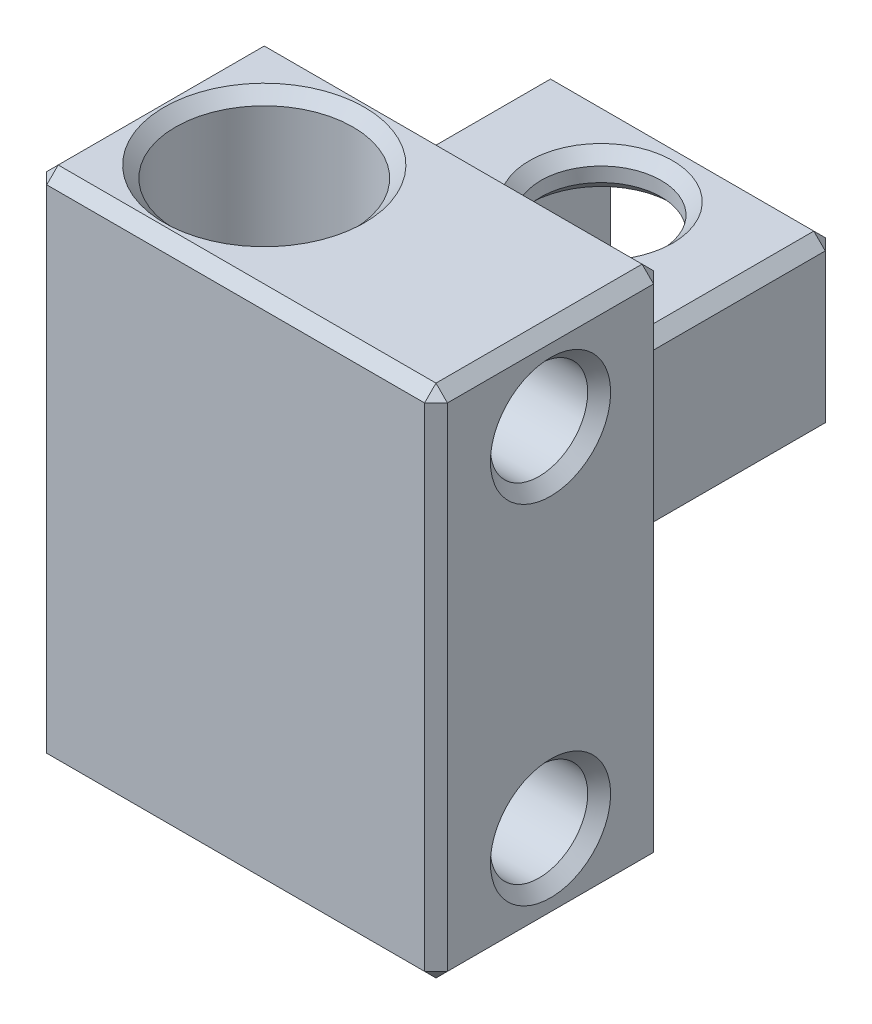
from build123d import *

# Parameters (mm, degrees)
SKETCH1_W               = 35
SKETCH1_H               = 20
BOSS_EXTRUDE1_DEPTH     = 45
SKETCH2_R               = 7.75
CUT_EXTRUDE1_DEPTH      = 46
SKETCH3_R               = 4.25
CUT_EXTRUDE2_DEPTH      = 10
SKETCH4_W               = 25
SKETCH4_H               = 15
BOSS_EXTRUDE2_DEPTH     = 25
SKETCH5_W               = 14.5
SKETCH5_H               = 16.25
CUT_EXTRUDE3_DEPTH      = 31
BOSS_EXTRUDE3_REACH     = 31.75
SKETCH6_W               = 16.25
SKETCH6_H               = 3.25
SKETCH7_R               = 5.25
CUT_EXTRUDE4_DEPTH      = 27.75
CUT_EXTRUDE4_DEPTH_BACK = 19.25
CHAMFER1_SIZE           = 1
CHAMFER2_SIZE           = 1


with BuildPart() as part:
    # Sketch1 → Boss-Extrude1 (new body)
    with BuildSketch(Plane(origin=(0, 0, 0), x_dir=(1, 0, 0), z_dir=(0, 1, 0))):
        with Locations((17.5, 10)):
            Rectangle(SKETCH1_W, SKETCH1_H)
    extrude(amount=BOSS_EXTRUDE1_DEPTH)

    # Sketch2 → Cut-Extrude1 (cut, through all)
    with BuildSketch(Plane(origin=(0, 45, 0), x_dir=(1, 0, 0), z_dir=(0, 1, 0))):
        with Locations((10, 10)):
            Circle(SKETCH2_R)
    extrude(amount=-CUT_EXTRUDE1_DEPTH, mode=Mode.SUBTRACT)

    # Sketch3 → Cut-Extrude2 (cut)
    with BuildSketch(Plane(origin=(35, 0, 0), x_dir=(0, 0, -1), z_dir=(1, 0, 0))):
        with Locations((10, 37.6875)):
            Circle(SKETCH3_R)
        with Locations((10, 7.3125)):
            Circle(SKETCH3_R)
    extrude(amount=-CUT_EXTRUDE2_DEPTH, mode=Mode.SUBTRACT)

    # Sketch4 → Boss-Extrude2 (add)
    with BuildSketch(Plane(origin=(0, 0, -20), x_dir=(-1, 0, 0), z_dir=(0, 0, -1))):
        with Locations((-12.5, 22.5)):
            Rectangle(SKETCH4_W, SKETCH4_H)
    extrude(amount=BOSS_EXTRUDE2_DEPTH)

    # Sketch5 → Cut-Extrude3 (cut, through all)
    with BuildSketch(Plane(origin=(0, 30, 0), x_dir=(1, 0, 0), z_dir=(0, 1, 0))):
        with Locations((12.5, 36.875)):
            Rectangle(SKETCH5_W, SKETCH5_H)
    extrude(amount=-CUT_EXTRUDE3_DEPTH, mode=Mode.SUBTRACT)

    # Sketch6 → Boss-Extrude3 (add, up to next)
    with BuildSketch(Plane(origin=(5.25, 0, 0), x_dir=(0, 0, -1), z_dir=(1, 0, 0)), mode=Mode.PRIVATE) as boss_extrude3_sk1:
        with Locations((36.875, 28.375)):
            Rectangle(SKETCH6_W, SKETCH6_H)
    boss_extrude3_tool1 = extrude(boss_extrude3_sk1.sketch, amount=BOSS_EXTRUDE3_REACH, mode=Mode.PRIVATE) - part.part
    add(boss_extrude3_tool1.solids().sort_by_distance((5.25, 28.375, -36.875))[0])
    # Sketch6 → Boss-Extrude3 (add, up to next)
    with BuildSketch(Plane(origin=(5.25, 0, 0), x_dir=(0, 0, -1), z_dir=(1, 0, 0)), mode=Mode.PRIVATE) as boss_extrude3_sk2:
        with Locations((36.875, 16.625)):
            Rectangle(SKETCH6_W, SKETCH6_H)
    boss_extrude3_tool2 = extrude(boss_extrude3_sk2.sketch, amount=BOSS_EXTRUDE3_REACH, mode=Mode.PRIVATE) - part.part
    add(boss_extrude3_tool2.solids().sort_by_distance((5.25, 16.625, -36.875))[0])

    # Sketch7 → Cut-Extrude4 (cut, two sides)
    with BuildSketch(Plane(origin=(0, 18.25, 0), x_dir=(1, 0, 0), z_dir=(0, 1, 0))) as cut_extrude4_sk:
        with Locations((12.5, 36.917096231)):
            Circle(SKETCH7_R)
    extrude(amount=CUT_EXTRUDE4_DEPTH, mode=Mode.SUBTRACT)
    extrude(cut_extrude4_sk.sketch, amount=-CUT_EXTRUDE4_DEPTH_BACK, mode=Mode.SUBTRACT)

    # Chamfer1
    chamfer1_edges = [part.edges().sort_by_distance(p)[0] for p in [
        (35, 45, -10),
        (2.25, 0, -10),
        (2.25, 45, -10),
        (17.5, 45, -20),
        (0, 7.5, -20),
        (0, 15, -32.5),
        (12.5, 30, -20),
        (0, 30, -32.5),
        (25, 22.5, -20),
        (25, 30, -32.5),
        (12.5, 15, -20),
        (25, 15, -32.5),
        (0, 22.5, -45),
        (12.5, 30, -45),
        (25, 22.5, -45),
        (12.5, 15, -45),
        (0, 45, -10),
        (17.5, 0, -20),
        (35, 0, -10),
        (17.5, 0, 0),
        (0, 0, -10),
        (0, 37.5, -20),
        (35, 22.5, -20),
        (35, 22.5, 0),
        (0, 22.5, 0),
        (7.25, 26.75, -36.917096231),
        (7.25, 30, -36.917096231),
        (7.25, 18.25, -36.917096231),
        (7.25, 15, -36.917096231),
        (17.5, 45, 0),
    ]]
    chamfer(chamfer1_edges, length=CHAMFER1_SIZE)

    # Chamfer2
    chamfer2_edges = [part.edges().sort_by_distance(p)[0] for p in [
        (35, 37.6875, -5.75),
        (35, 7.3125, -5.75),
    ]]
    chamfer(chamfer2_edges, length=CHAMFER2_SIZE)


solid = part.part
